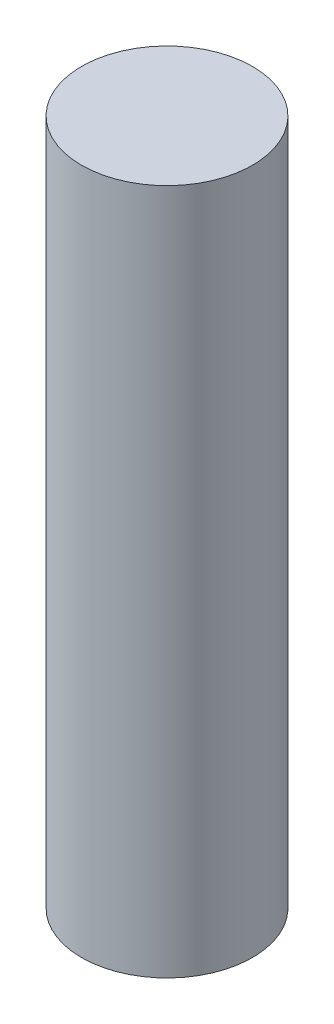
from build123d import *

# Parameters (mm, degrees)
SKETCH1_R           = 2.3749
BOSS_EXTRUDE1_DEPTH = 19.05


with BuildPart() as part:
    # Sketch1 → Boss-Extrude1 (new body)
    with BuildSketch(Plane(origin=(0, 0, 0), x_dir=(1, 0, 0), z_dir=(0, 1, 0))):
        Circle(SKETCH1_R)
    extrude(amount=BOSS_EXTRUDE1_DEPTH)


solid = part.part
